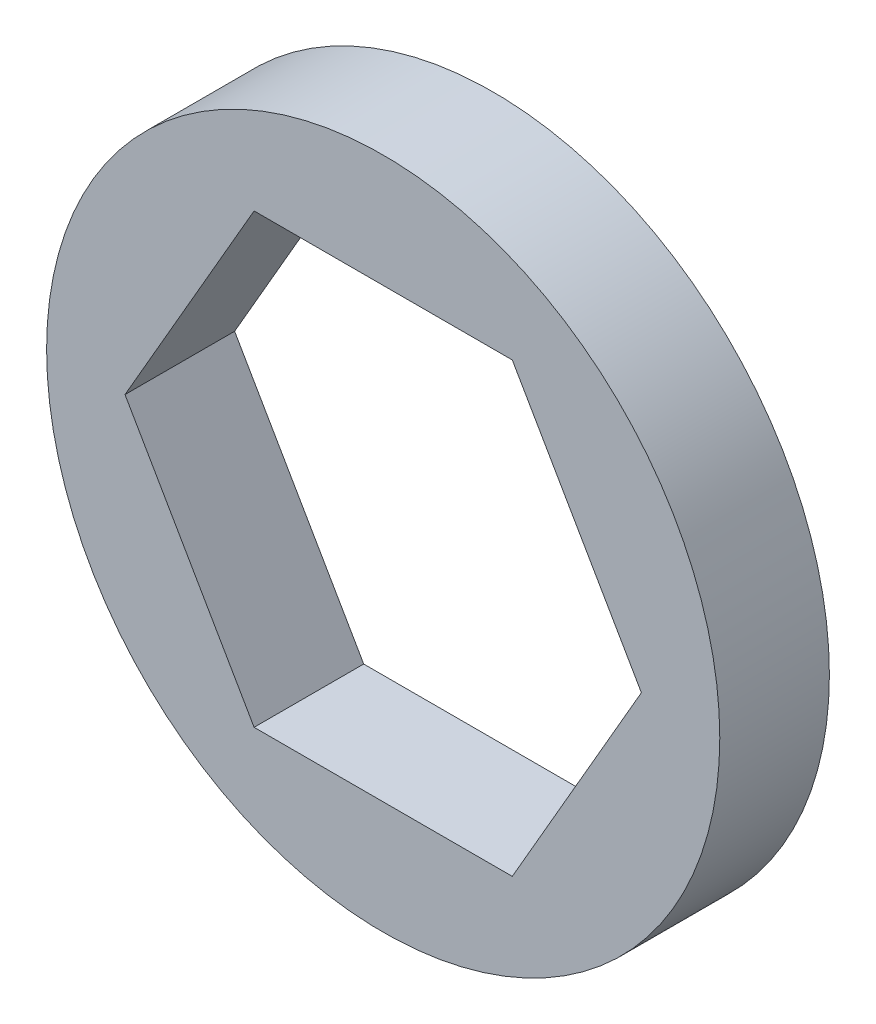
from build123d import *

# Parameters (mm, degrees)
SKETCH1_R           = 9.75
BOSS_EXTRUDE1_DEPTH = 3.175


with BuildPart() as part:
    # Sketch1 → Boss-Extrude1 (new body)
    with BuildSketch(Plane.XY.offset(3.175)):
        Circle(SKETCH1_R)
        Polygon((-3.739497694, 6.477), (3.739497694, 6.477), (7.478995387, 0), (3.739497694, -6.477), (-3.739497694, -6.477), (-7.478995387, 0), align=None, mode=Mode.SUBTRACT)
    extrude(amount=-BOSS_EXTRUDE1_DEPTH)


solid = part.part
